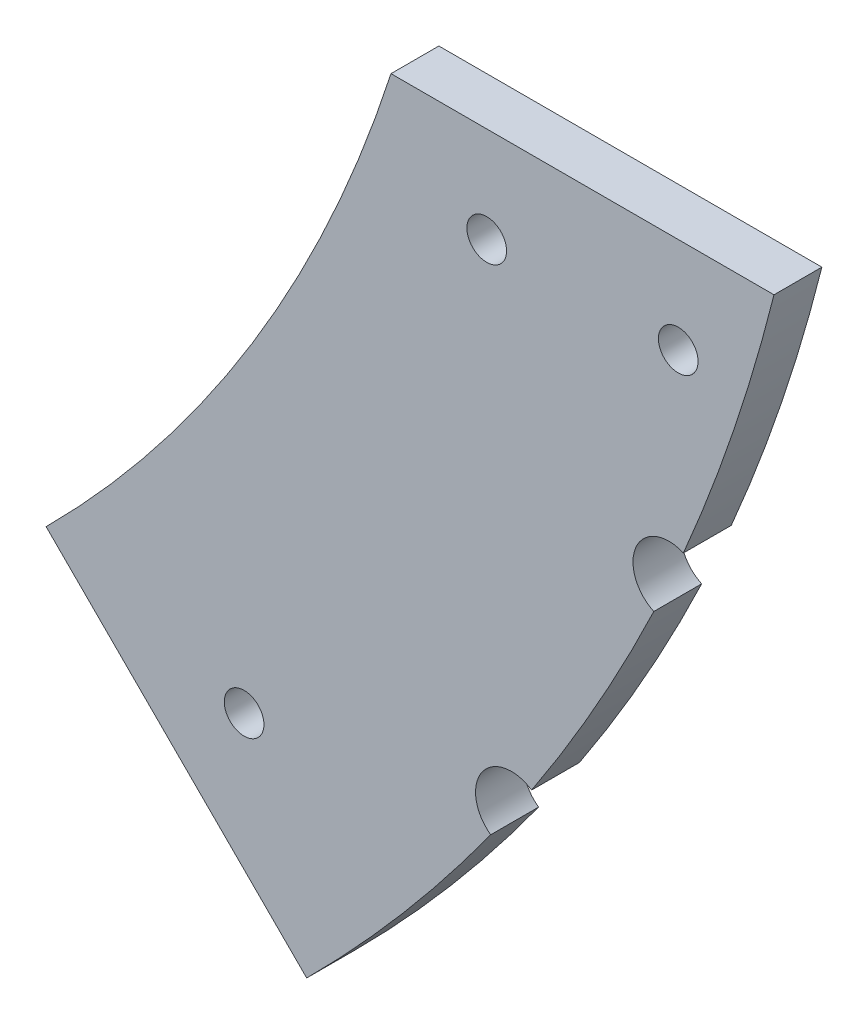
from build123d import *

# Parameters (mm, degrees)
SKETCH1_R           = 2.6289
BOSS_EXTRUDE1_DEPTH = 6.35
SKETCH2_R           = 4.7625
CUT_EXTRUDE1_DEPTH  = 6.35


with BuildPart() as part:
    # Sketch1 → Boss-Extrude1 (new body)
    with BuildSketch(Plane.XY):
        with BuildLine():
            Line((177.8, -57.15), (228.6, -57.15))
            ThreePointArc((228.6, -57.15), (205.049978384, -116.097324969), (166.619450395, -166.619450395))
            Line((166.619450395, -166.619450395), (132.058628079, -132.058628079))
            ThreePointArc((132.058628079, -132.058628079), (159.392339806, -97.32956648), (177.8, -57.15))
        make_face()
        with Locations((190.5, -69.85)):
            Circle(SKETCH1_R, mode=Mode.SUBTRACT)
        with Locations((215.9, -69.85)):
            Circle(SKETCH1_R, mode=Mode.SUBTRACT)
        with Locations((158.319295358, -140.358783116)):
            Circle(SKETCH1_R, mode=Mode.SUBTRACT)
    extrude(amount=BOSS_EXTRUDE1_DEPTH)

    # Sketch2 → Cut-Extrude1 (cut)
    with BuildSketch(Plane.XY.offset(6.35)):
        with Locations((193.77605394, -134.07059118)):
            Circle(SKETCH2_R)
        with Locations((214.661540739, -97.182845336)):
            Circle(SKETCH2_R)
    extrude(amount=-CUT_EXTRUDE1_DEPTH, mode=Mode.SUBTRACT)


solid = part.part
